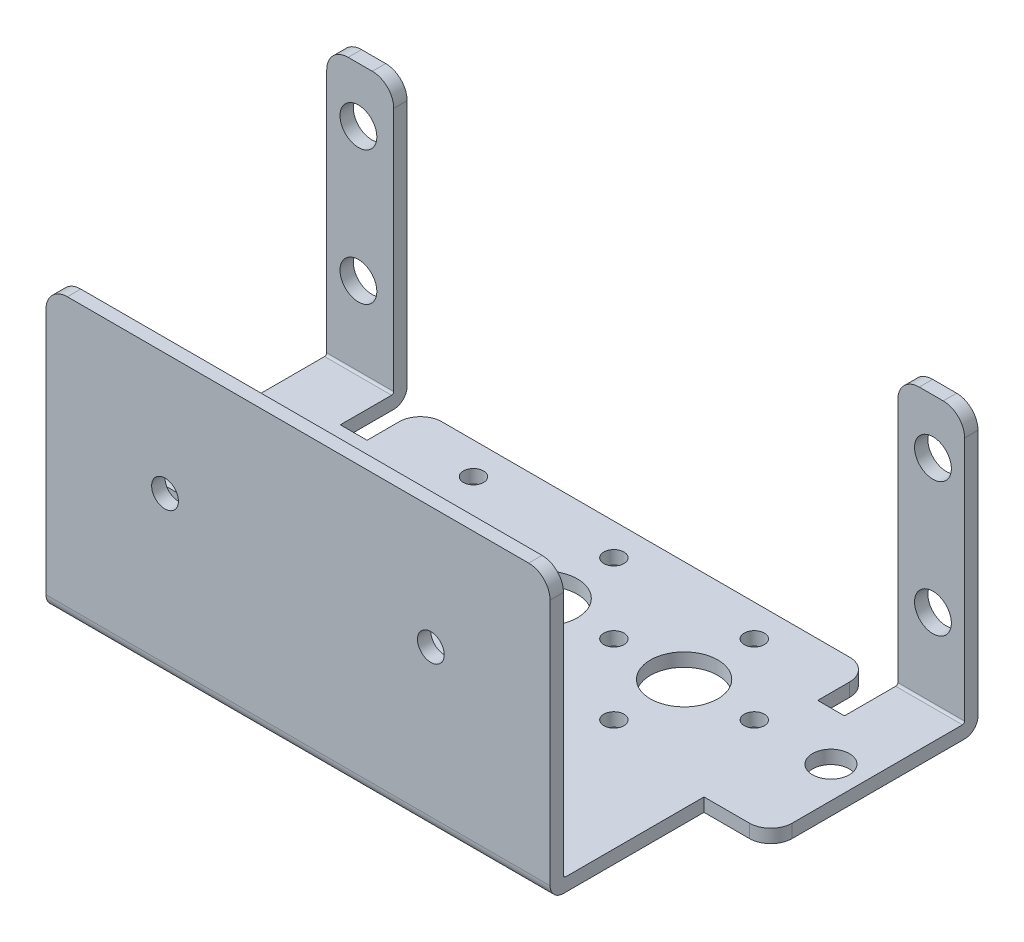
from build123d import *

# Parameters (mm, degrees)
EXTRUDE1_DEPTH             = 75.692
SKETCH2_W                  = 7.9502
SKETCH2_H                  = 18.2626
SKETCH2_W_2                = 7.9248
EXTRUDE2_DEPTH             = 33.4772
EXTRUDE3_REACH             = 33.89
SKETCH3_W                  = 59.817
SKETCH3_H                  = 1.5875
EXTRUDE3_DIRECTION_2_REACH = 3.588
SKETCH4_W                  = 3.175
SKETCH4_H                  = 6.3373
EXTRUDE4_DEPTH             = 1.5875
SKETCH5_R                  = 4.0005
SKETCH5_R_2                = 1.1938
SKETCH5_R_3                = 2.1844
EXTRUDE5_DEPTH             = 1.5875
SKETCH6_R                  = 2.1844
SKETCH6_R_2                = 1.5875
EXTRUDE6_DEPTH             = 43.8498
FILLET1_R                  = 2.54
FILLET2_R                  = 0.254
FILLET3_R                  = 2.54
FILLET4_R                  = 2.54


with BuildPart() as part:
    # Sketch1 → Extrude1 (new body)
    with BuildSketch(Plane(origin=(0, 0, 0), x_dir=(0, 0, -1), z_dir=(1, 0, 0))):
        with BuildLine():
            Line((1.5875, 33.4772), (1.5875, 1.5875))
            Line((1.5875, 1.5875), (41.2623, 1.5875))
            Line((41.2623, 1.5875), (41.2623, 33.4772))
            Line((41.2623, 33.4772), (42.8498, 33.4772))
            Line((42.8498, 33.4772), (42.8498, 1.5875))
            ThreePointArc((42.8498, 1.5875), (42.384832015, 0.464967985), (41.2623, 0))
            Line((41.2623, 0), (1.5875, 0))
            ThreePointArc((1.5875, 0), (0.464967985, 0.464967985), (0, 1.5875))
            Line((0, 1.5875), (0, 33.4772))
            Line((0, 33.4772), (1.5875, 33.4772))
        make_face()
    extrude(amount=EXTRUDE1_DEPTH)

    # Sketch2 → Extrude2 (cut)
    with BuildSketch(Plane(origin=(0, 33.4772, 0), x_dir=(1, 0, 0), z_dir=(0, 1, 0))):
        with Locations((3.9751, 9.1313)):
            Rectangle(SKETCH2_W, SKETCH2_H)
        with Locations((71.7296, 9.1313)):
            Rectangle(SKETCH2_W_2, SKETCH2_H)
    extrude(amount=-EXTRUDE2_DEPTH, mode=Mode.SUBTRACT)

    # Extrude3: up to this face of the body (flat: up to its plane)
    extrude3_end = Plane(part.part.faces().sort_by_distance((37.846, 33.4772, -42.05605))[0])
    # Sketch3 → Extrude3 (cut, up to the picked face)
    with BuildSketch(Plane(origin=(0, 1.5875, 0), x_dir=(1, 0, 0), z_dir=(0, 1, 0)), mode=Mode.PRIVATE) as extrude3_sk1:
        with Locations((37.8587, 42.05605)):
            Rectangle(SKETCH3_W, SKETCH3_H)
    extrude3_tool1 = split(extrude(extrude3_sk1.sketch, amount=EXTRUDE3_REACH, mode=Mode.PRIVATE), bisect_by=extrude3_end, keep=Keep.BOTH, mode=Mode.PRIVATE)
    add(extrude3_tool1.solids().sort_by(Axis((37.8587, 1.5875, -42.05605), (0, 1, 0)))[0], mode=Mode.SUBTRACT)

    # Extrude3 direction 2: up to this face of the body (flat: up to its plane)
    extrude3_direction_2_end = Plane(part.part.faces().sort_by_distance((37.850626027, 0, -22.536595268))[0])
    # Sketch3 → Extrude3 direction 2 (cut, up to the picked face)
    with BuildSketch(Plane(origin=(0, 1.5875, 0), x_dir=(1, 0, 0), z_dir=(0, 1, 0)), mode=Mode.PRIVATE) as extrude3_direction_2_sk1:
        with Locations((37.8587, 42.05605)):
            Rectangle(SKETCH3_W, SKETCH3_H)
    extrude3_direction_2_tool1 = split(extrude(extrude3_direction_2_sk1.sketch, amount=-EXTRUDE3_DIRECTION_2_REACH, mode=Mode.PRIVATE), bisect_by=extrude3_direction_2_end, keep=Keep.BOTH, mode=Mode.PRIVATE)
    add(extrude3_direction_2_tool1.solids().sort_by(Axis((37.8587, 1.5875, -42.05605), (0, -1, 0)))[0], mode=Mode.SUBTRACT)

    # Sketch4 → Extrude4 (cut)
    with BuildSketch(Plane(origin=(0, 1.5875, 0), x_dir=(1, 0, 0), z_dir=(0, 1, 0))):
        with Locations((9.5377, 38.09365)):
            Rectangle(SKETCH4_W, SKETCH4_H)
        with Locations((66.1797, 38.09365)):
            Rectangle(SKETCH4_W, SKETCH4_H)
    extrude(amount=-EXTRUDE4_DEPTH, mode=Mode.SUBTRACT)

    # Sketch5 → Extrude5 (cut)
    with BuildSketch(Plane(origin=(0, 1.5875, 0), x_dir=(1, 0, 0), z_dir=(0, 1, 0))):
        with Locations(Location((21.1836, 29.1592, 0), (0, 0, 270))):  # turned: the seam where the file's is
            Circle(SKETCH5_R)
        with Locations(Location((21.1836, 37.4904, 0), (0, 0, 270))):  # turned: the seam where the file's is
            Circle(SKETCH5_R_2)
        with Locations(Location((12.8524, 29.1592, 0), (0, 0, 270))):  # turned: the seam where the file's is
            Circle(SKETCH5_R_2)
        with Locations(Location((21.1836, 20.828, 0), (0, 0, 270))):  # turned: the seam where the file's is
            Circle(SKETCH5_R_2)
        with Locations(Location((37.846, 37.4904, 0), (0, 0, 270))):  # turned: the seam where the file's is
            Circle(SKETCH5_R_2)
        with Locations(Location((29.5148, 29.1592, 0), (0, 0, 270))):  # turned: the seam where the file's is
            Circle(SKETCH5_R_2)
        with Locations(Location((37.846, 20.828, 0), (0, 0, 270))):  # turned: the seam where the file's is
            Circle(SKETCH5_R_2)
        with Locations(Location((37.846, 29.1592, 0), (0, 0, 270))):  # turned: the seam where the file's is
            Circle(SKETCH5_R)
        with Locations(Location((54.5084, 20.828, 0), (0, 0, 270))):  # turned: the seam where the file's is
            Circle(SKETCH5_R_2)
        with Locations(Location((54.5084, 29.1592, 0), (0, 0, 270))):  # turned: the seam where the file's is
            Circle(SKETCH5_R)
        with Locations(Location((46.1772, 29.1592, 0), (0, 0, 270))):  # turned: the seam where the file's is
            Circle(SKETCH5_R_2)
        with Locations(Location((54.5084, 37.4904, 0), (0, 0, 270))):  # turned: the seam where the file's is
            Circle(SKETCH5_R_2)
        with Locations(Location((62.8396, 29.1592, 0), (0, 0, 270))):  # turned: the seam where the file's is
            Circle(SKETCH5_R_2)
        with Locations(Location((3.7592, 29.1592, 0), (0, 0, 270))):  # turned: the seam where the file's is
            Circle(SKETCH5_R_3)
        with Locations(Location((71.9328, 29.1592, 0), (0, 0, 270))):  # turned: the seam where the file's is
            Circle(SKETCH5_R_3)
    extrude(amount=-EXTRUDE5_DEPTH, mode=Mode.SUBTRACT)

    # Sketch6 → Extrude6 (cut, through all)
    with BuildSketch(Plane.XY):
        with Locations((3.7592, 27.0002)):
            Circle(SKETCH6_R)
        with Locations((3.7592, 11.1252)):
            Circle(SKETCH6_R)
        with Locations((71.9328, 27.0002)):
            Circle(SKETCH6_R)
        with Locations((71.9328, 11.1252)):
            Circle(SKETCH6_R)
        with Locations((22.0726, 19.05)):
            Circle(SKETCH6_R_2)
        with Locations((53.6194, 19.05)):
            Circle(SKETCH6_R_2)
    extrude(amount=-EXTRUDE6_DEPTH, mode=Mode.SUBTRACT)

    # Fillet1
    fillet1_edges = [part.edges().sort_by_distance(p)[0] for p in [
        (64.5922, 0.79375, -41.2623),
        (0, 33.4772, -42.05605),
        (7.9502, 33.4772, -0.79375),
        (75.692, 33.4772, -42.05605),
        (75.692, 0.79375, -18.2626),
        (67.7672, 33.4772, -0.79375),
        (11.1252, 0.79375, -41.2623),
    ]]
    fillet(fillet1_edges, radius=FILLET1_R)

    # Fillet2
    fillet2_edges = [part.edges().sort_by_distance(p)[0] for p in [
        (71.7296, 1.5875, -41.2623),
        (37.8587, 1.5875, -1.5875),
        (3.9751, 1.5875, -41.2623),
    ]]
    fillet(fillet2_edges, radius=FILLET2_R)

    # Fillet3
    fillet3_edges = [part.edges().sort_by_distance(p)[0] for p in [
        (0, 0.79375, -18.2626),
    ]]
    fillet(fillet3_edges, radius=FILLET3_R)

    # Fillet4
    fillet4_edges = [part.edges().sort_by_distance(p)[0] for p in [
        (67.7672, 33.4772, -42.05605),
        (7.9502, 33.4772, -42.05605),
    ]]
    fillet(fillet4_edges, radius=FILLET4_R)


solid = part.part
